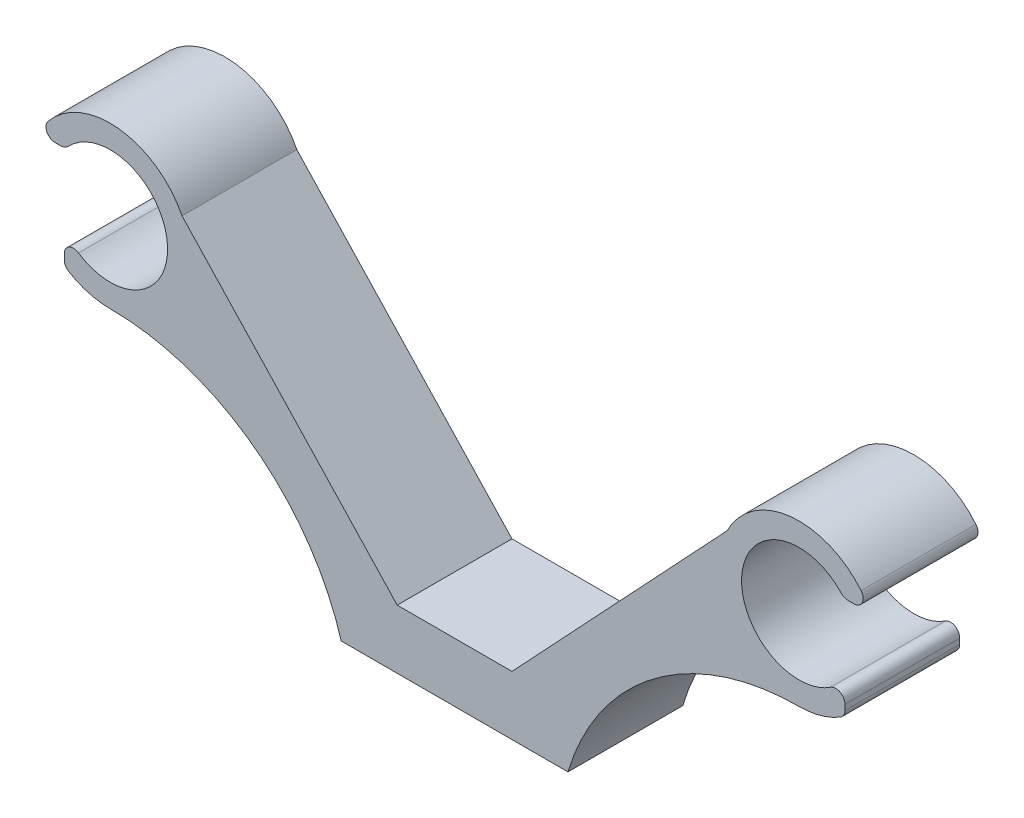
from build123d import *

# Parameters (mm, degrees)
BOSS_EXTRUDE1_DEPTH = 10


with BuildPart() as part:
    # Sketch1 → Boss-Extrude1 (new body)
    with BuildSketch(Plane.XY):
        with BuildLine():
            Line((9.875388203, 0), (-9.875388203, 0))
            ThreePointArc((-9.875388203, 0), (-17.450099602, 10.83745824), (-30, 15))
            ThreePointArc((-30, 15), (-31.8749625, 15.255779094), (-33.612903226, 16.004424108))
            ThreePointArc((-33.612903226, 16.004424108), (-33.896535204, 16.29613728), (-34, 16.689632781))
            Line((-34, 16.689632781), (-34, 17.162645351))
            ThreePointArc((-34, 17.162645351), (-33.578745661, 17.867309614), (-32.75862069, 17.829866682))
            ThreePointArc((-32.75862069, 17.829866682), (-25.031925557, 22.564124391), (-33.623370468, 25.445458816))
            ThreePointArc((-33.623370468, 25.445458816), (-33.953767859, 25.215558804), (-34.348044562, 25.134550579))
            Line((-34.348044562, 25.134550579), (-34.791587602, 25.134550579))
            ThreePointArc((-34.791587602, 25.134550579), (-35.51482586, 25.592605522), (-35.409856969, 26.442234524))
            ThreePointArc((-35.409856969, 26.442234524), (-29.220414383, 28.95645357), (-23.74103901, 25.134550579))
            Line((-23.74103901, 25.134550579), (-5, 5.145359938))
            Line((-5, 5.145359938), (5, 5.145359938))
            Line((5, 5.145359938), (23.74103901, 25.134550579))
            ThreePointArc((23.74103901, 25.134550579), (29.220414383, 28.95645357), (35.409856969, 26.442234524))
            ThreePointArc((35.409856969, 26.442234524), (35.51482586, 25.592605522), (34.791587602, 25.134550579))
            Line((34.791587602, 25.134550579), (34.348044562, 25.134550579))
            ThreePointArc((34.348044562, 25.134550579), (33.953767859, 25.215558804), (33.623370468, 25.445458816))
            ThreePointArc((33.623370468, 25.445458816), (25.031925557, 22.564124391), (32.75862069, 17.829866682))
            ThreePointArc((32.75862069, 17.829866682), (33.578745661, 17.867309614), (34, 17.162645351))
            Line((34, 17.162645351), (34, 16.689632781))
            ThreePointArc((34, 16.689632781), (33.896535204, 16.29613728), (33.612903226, 16.004424108))
            ThreePointArc((33.612903226, 16.004424108), (31.8749625, 15.255779094), (30, 15))
            ThreePointArc((30, 15), (17.450099602, 10.83745824), (9.875388203, 0))
        make_face()
    extrude(amount=BOSS_EXTRUDE1_DEPTH)


solid = part.part
